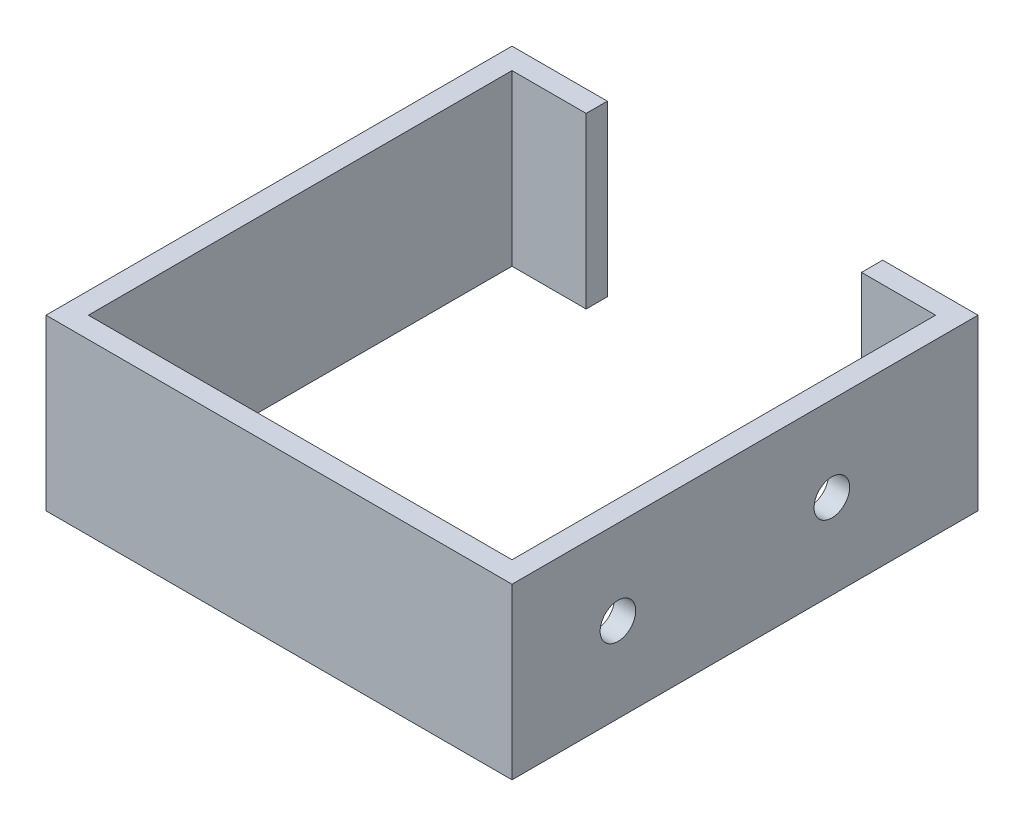
from build123d import *

# Parameters (mm, degrees)
BOSS_EXTRUDE1_DEPTH = 25.4
CUT_EXTRUDE1_REACH  = 71.85
SKETCH2_R           = 2.667


with BuildPart() as part:
    # Sketch1 → Boss-Extrude1 (new body)
    with BuildSketch(Plane(origin=(0, 0, 0), x_dir=(1, 0, 0), z_dir=(0, 1, 0))):
        Polygon((-3.175, -3.175), (-3.175, 63.5), (-3.175, 66.675), (11.1125, 66.675), (11.1125, 63.5), (0, 63.5), (0, 0), (63.5, 0), (63.5, 63.5), (52.3875, 63.5), (52.3875, 66.675), (66.675, 66.675), (66.675, 63.5), (66.675, -3.175), align=None)
    extrude(amount=BOSS_EXTRUDE1_DEPTH)

    # Sketch2 → Cut-Extrude1 (cut, up to next)
    with BuildSketch(Plane(origin=(66.675, 0, 0), x_dir=(0, 0, -1), z_dir=(1, 0, 0)), mode=Mode.PRIVATE) as cut_extrude1_sk1:
        with Locations((12.7, 12.7)):
            Circle(SKETCH2_R)
    cut_extrude1_tool1 = extrude(cut_extrude1_sk1.sketch, amount=-CUT_EXTRUDE1_REACH, mode=Mode.PRIVATE) & part.part
    add(cut_extrude1_tool1.solids().sort_by_distance((66.675, 12.7, -12.7))[0], mode=Mode.SUBTRACT)
    # Sketch2 → Cut-Extrude1 (cut, up to next)
    with BuildSketch(Plane(origin=(66.675, 0, 0), x_dir=(0, 0, -1), z_dir=(1, 0, 0)), mode=Mode.PRIVATE) as cut_extrude1_sk2:
        with Locations((44.7675, 12.7)):
            Circle(SKETCH2_R)
    cut_extrude1_tool2 = extrude(cut_extrude1_sk2.sketch, amount=-CUT_EXTRUDE1_REACH, mode=Mode.PRIVATE) & part.part
    add(cut_extrude1_tool2.solids().sort_by_distance((66.675, 12.7, -44.7675))[0], mode=Mode.SUBTRACT)


solid = part.part
